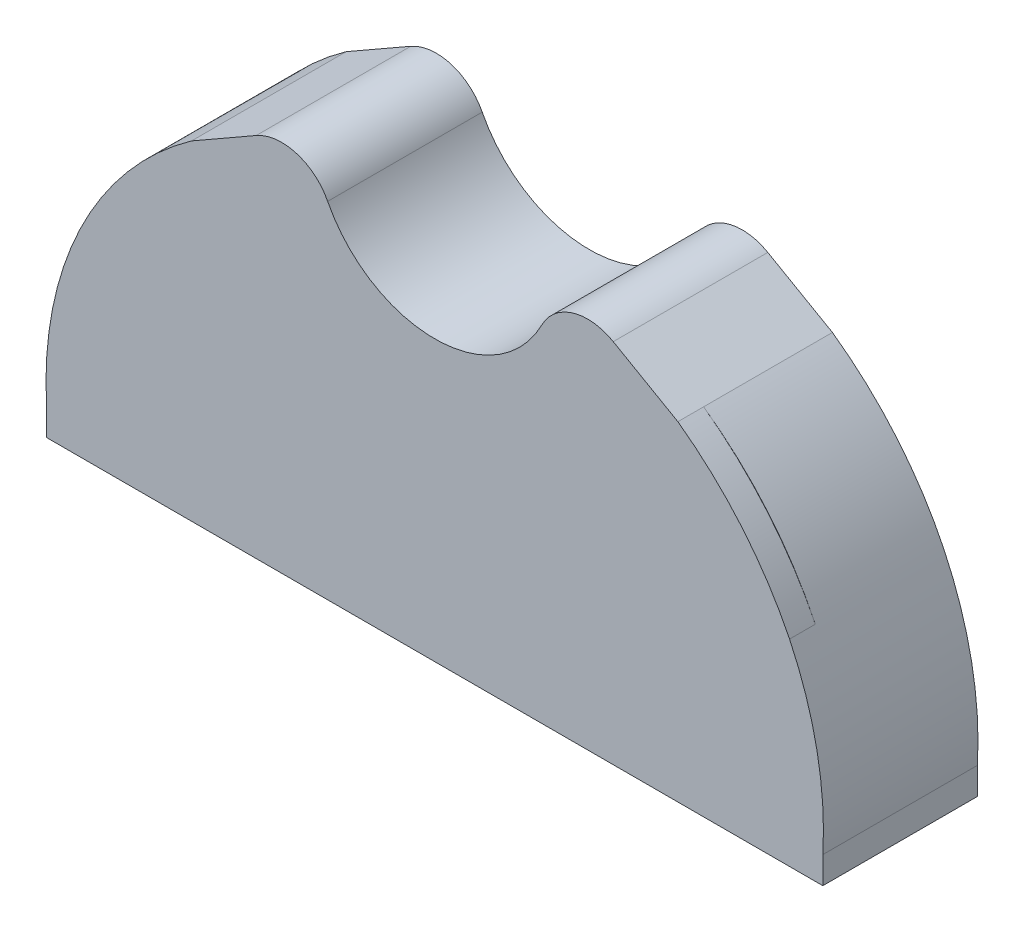
from build123d import *

# Parameters (mm, degrees)
BOSS_EXTRUDE1_DEPTH      = 0.915069
BOSS_EXTRUDE1_DEPTH_BACK = 2.834931
FILLET1_R                = 1.5
BOSS_EXTRUDE2_DEPTH      = 0.75


with BuildPart() as part:
    # Sketch1 → Boss-Extrude1 (new body, two sides)
    with BuildSketch(Plane.XY) as boss_extrude1_sk:
        with BuildLine():
            Line((7.72784891, 5.099738578), (7.72784891, 4.315453477))
            Line((7.72784891, 4.315453477), (6.47784891, 4.315453477))
            Line((6.47784891, 4.315453477), (6.47784891, 5.099738578))
            ThreePointArc((6.47784891, 5.099738578), (7.446291457, 10.050539659), (10.698263175, 13.90709152))
            Line((10.698263175, 13.90709152), (14.27784891, 15.955670445))
            ThreePointArc((14.27784891, 15.955670445), (17.77784891, 12.455670445), (21.27784891, 15.955670445))
            Line((21.27784891, 15.955670445), (24.857434644, 13.90709152))
            ThreePointArc((24.857434644, 13.90709152), (28.109406362, 10.050539659), (29.07784891, 5.099738578))
            Line((29.07784891, 5.099738578), (29.07784891, 4.315453477))
            Line((29.07784891, 4.315453477), (27.82784891, 4.315453477))
            Line((27.82784891, 4.315453477), (27.82784891, 5.099738578))
            ThreePointArc((27.82784891, 5.099738578), (26.841010044, 9.442734118), (24.074294629, 12.932826814))
            ThreePointArc((24.074294629, 12.932826814), (22.313278152, 13.328845303), (20.921800097, 12.179150343))
            ThreePointArc((20.921800097, 12.179150343), (17.77784891, 10.149738578), (14.633897723, 12.179150343))
            ThreePointArc((14.633897723, 12.179150343), (13.242419668, 13.328845303), (11.48140319, 12.932826814))
            ThreePointArc((11.48140319, 12.932826814), (8.714687776, 9.442734118), (7.72784891, 5.099738578))
        make_face()
    extrude(amount=BOSS_EXTRUDE1_DEPTH)
    extrude(boss_extrude1_sk.sketch, amount=-BOSS_EXTRUDE1_DEPTH_BACK)

    # Fillet1
    fillet1_edges = [part.edges().sort_by_distance(p)[0] for p in [
        (21.27784891, 15.955670445, -0.959931),
        (14.27784891, 15.955670445, -0.959931),
    ]]
    fillet(fillet1_edges, radius=FILLET1_R)

    # Sketch3 → Boss-Extrude2 (add)
    with BuildSketch(Plane.XY.offset(0.915069038)):
        with BuildLine():
            Line((12.579684297, 14.983819371), (10.698263175, 13.90709152))
            ThreePointArc((10.698263175, 13.90709152), (7.446291457, 10.050539659), (6.47784891, 5.099738578))
            Line((6.47784891, 5.099738578), (6.47784891, 4.315453477))
            Line((6.47784891, 4.315453477), (29.07784891, 4.315453477))
            Line((29.07784891, 4.315453477), (29.07784891, 5.099738578))
            ThreePointArc((29.07784891, 5.099738578), (28.909313649, 7.636891502), (28.109406362, 10.050539659))
            ThreePointArc((28.109406362, 10.050539659), (26.72021242, 12.178486343), (24.857434644, 13.90709152))
            Line((24.857434644, 13.90709152), (22.976013523, 14.983819371))
            ThreePointArc((22.976013523, 14.983819371), (21.80280977, 15.119540101), (20.895023154, 14.364059709))
            ThreePointArc((20.895023154, 14.364059709), (17.77784891, 12.455670445), (14.660674666, 14.364059709))
            ThreePointArc((14.660674666, 14.364059709), (13.75288805, 15.119540101), (12.579684297, 14.983819371))
        make_face()
    extrude(amount=BOSS_EXTRUDE2_DEPTH)


solid = part.part
